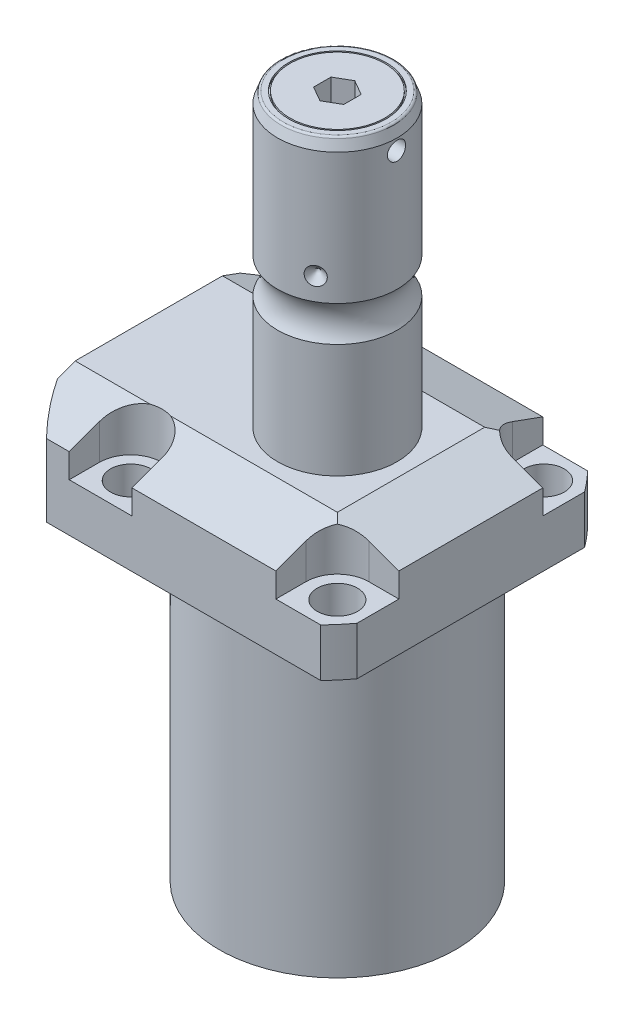
from build123d import *

# Parameters (mm, degrees)
SKETCH1_W               = 70.866
SKETCH1_H               = 85.496
EXTRUDE1_DEPTH          = 104.4448
SKETCH2_OUTSIDE_W       = 117.986
SKETCH2_OUTSIDE_H       = 103.356
SKETCH2_OUTSIDE_R       = 50.8
CUT_EXTRUDE1_DEPTH      = 105.4448
SKETCH3_W               = 45.1992
SKETCH3_H               = 79.4258
FILLET1_R               = 0.381
CUT_EXTRUDE2_DEPTH      = 12.243
CUT_EXTRUDE9_START      = -51.063
CUT_EXTRUDE9_DEPTH      = 87.496
CUT_EXTRUDE7_DEPTH      = 36.433
CUT_EXTRUDE7_DEPTH_BACK = 36.433
SKETCH10_R              = 1.1811
SKETCH17_W              = 5.3594
SKETCH17_H              = 12.776
HOLE1_AT_2_COUNT        = 2
HOLE1_AT_2_PITCH        = 54.864
HOLE1_AT_3_COUNT        = 2
HOLE1_AT_3_PITCH        = 77.589412886
HOLE1_AT_4_COUNT        = 2
HOLE1_AT_4_PITCH        = 54.864
CHAMFER1_SIZE           = 0.635
SKETCH22_R              = 6.35
EXTRUDE2_DEPTH          = 1.651
FILLET2_R               = 0.635
SKETCH24_R              = 12.954
SKETCH24_R_2            = 12.573
CUT_EXTRUDE10_DEPTH     = 0.49999999
CUT_EXTRUDE11_DEPTH     = 8
CIRPATTERN1_COUNT       = 3
SKETCH27_W              = 3.81
SKETCH27_H              = 2.413
CHAMFER2_SIZE           = 1.016


with BuildPart() as part:
    # Sketch1 → Extrude1 (new body)
    with BuildSketch(Plane(origin=(0, 0, 0), x_dir=(0, 0, 1), z_dir=(0, -1, 0))):
        with Locations((0, 7.315)):
            Rectangle(SKETCH1_W, SKETCH1_H)
    extrude(amount=-EXTRUDE1_DEPTH)

    # Sketch2 outside → Cut-Extrude1 (cut, through all)
    with BuildSketch(Plane.XZ):
        with Locations((-7.315, 0)):
            Rectangle(SKETCH2_OUTSIDE_W, SKETCH2_OUTSIDE_H)
        with Locations((-5.4102, 0)):
            Circle(SKETCH2_OUTSIDE_R, mode=Mode.SUBTRACT)
    extrude(amount=-CUT_EXTRUDE1_DEPTH, mode=Mode.SUBTRACT)

    # Sketch3 → Cut-Revolve1 (revolve, cut)
    with BuildSketch(Plane(origin=(0, 0, 0), x_dir=(0, 0, -1), z_dir=(1, 0, 0))):
        with Locations((53.9941, 39.7129)):
            Rectangle(SKETCH3_W, SKETCH3_H)
    revolve(axis=Axis((0, -93.345, 0), (0, 1, 0)), mode=Mode.SUBTRACT)

    # Fillet1
    fillet1_edges = [part.edges().sort_by_distance(p)[0] for p in [
        (0, 79.4258, 31.3945),
    ]]
    fillet(fillet1_edges, radius=FILLET1_R)

    # Sketch4 → Cut-Extrude2 (cut)
    with BuildSketch(Plane(origin=(0, 104.4448, 0), x_dir=(-1, 0, 0), z_dir=(0, 1, 0))):
        with BuildLine():
            Line((-19.1008, -35.433), (-19.1008, -27.432))
            ThreePointArc((-19.1008, -27.432), (-21.540951985, -21.540951985), (-27.432, -19.1008))
            Line((-27.432, -19.1008), (-35.433, -19.1008))
            Line((-35.433, -19.1008), (-35.433, -35.433))
            Line((-35.433, -35.433), (-19.1008, -35.433))
        make_face()
        with BuildLine():
            Line((35.7632, -35.433), (19.1008, -35.433))
            Line((19.1008, -35.433), (19.1008, -27.432))
            ThreePointArc((19.1008, -27.432), (27.432, -19.1008), (35.7632, -27.432))
            Line((35.7632, -27.432), (35.7632, -35.433))
        make_face()
        with BuildLine():
            Line((19.1008, 35.433), (19.1008, 27.432))
            ThreePointArc((19.1008, 27.432), (27.432, 19.1008), (35.7632, 27.432))
            Line((35.7632, 27.432), (35.7632, 35.433))
            Line((35.7632, 35.433), (19.1008, 35.433))
        make_face()
        with BuildLine():
            Line((-27.432, 19.1008), (-35.433, 19.1008))
            Line((-35.433, 19.1008), (-35.433, 35.433))
            Line((-35.433, 35.433), (-19.1008, 35.433))
            Line((-19.1008, 35.433), (-19.1008, 27.432))
            ThreePointArc((-19.1008, 27.432), (-21.540951985, 21.540951985), (-27.432, 19.1008))
        make_face()
    extrude(amount=-CUT_EXTRUDE2_DEPTH, mode=Mode.SUBTRACT)

    # Sketch5 → Cut-Extrude9 (cut)
    with BuildSketch(Plane(origin=(0, 0, 0), x_dir=(0, 0, -1), z_dir=(1, 0, 0)).offset(CUT_EXTRUDE9_START)):
        Polygon((-19.558, 104.4448), (-35.433, 98.666772531), (-35.433, 104.4448), align=None)
    cut_extrude9 = extrude(amount=CUT_EXTRUDE9_DEPTH, mode=Mode.SUBTRACT)

    # Mirror1: Cut-Extrude9 across plane
    add(cut_extrude9.mirror(Plane.XY), mode=Mode.SUBTRACT)

    # Sketch9 → Cut-Extrude7 (cut, two sides)
    with BuildSketch(Plane.XY) as cut_extrude7_sk:
        Polygon((19.558, 104.4448), (35.433, 98.666772531), (35.433, 104.4448), align=None)
    extrude(amount=CUT_EXTRUDE7_DEPTH, mode=Mode.SUBTRACT)
    extrude(cut_extrude7_sk.sketch, amount=-CUT_EXTRUDE7_DEPTH_BACK, mode=Mode.SUBTRACT)

    # Sketch20 → Cut-Revolve4 (revolve, cut)
    with BuildSketch(Plane(origin=(-35.0774, 88.9, -18.1102), x_dir=(0, 1, 0), z_dir=(1, 0, 0)), mode=Mode.PRIVATE) as cut_revolve4_sk:
        Polygon((-9.4742, 38.3413), (-8.0264, 38.3413), (-8.0264, 35.8902), (-7.0104, 35.8902), (-7.0104, 33.8836), (3.9624, 33.8836), (3.9624, 32.639), (-9.4742, 32.639), align=None)
    cut_revolve4 = revolve(cut_revolve4_sk.sketch.rotate(Axis((-35.0774, 81.620304954, 14.5288), (0, 1, 0)), 180), axis=Axis((-35.0774, 81.620304954, 14.5288), (0, 1, 0)), mode=Mode.SUBTRACT)  # turned: the seam where the file's is

    # Mirror10: Cut-Revolve4 across plane
    add(cut_revolve4.mirror(Plane.XY), mode=Mode.SUBTRACT)

    # Sketch15 → Revolve3 (revolve)
    with BuildSketch(Plane(origin=(0, 0, 0), x_dir=(0, 0, -1), z_dir=(1, 0, 0)), mode=Mode.PRIVATE) as revolve3_sk:
        with BuildLine():
            Line((0, 104.4448), (15.875, 104.4448))
            Line((15.875, 104.4448), (15.875, 134.68810643))
            ThreePointArc((15.875, 134.68810643), (14.3256, 139.3952), (15.875, 144.10229357))
            Line((15.875, 144.10229357), (15.875, 178.89219416))
            Line((15.875, 178.89219416), (14.81184082, 181.8132))
            Line((14.81184082, 181.8132), (0, 181.8132))
            Line((0, 181.8132), (0, 104.4448))
        make_face()
    revolve(revolve3_sk.sketch.rotate(Axis((0, 250.290824608, 0), (0, -1, 0)), 180), axis=Axis((0, 250.290824608, 0), (0, -1, 0)))  # turned: the seam where the file's is

    # Sketch17 → Hole1 (revolve, cut)
    with BuildSketch(Plane(origin=(27.432, 92.2018, -27.432), x_dir=(0, 0, 1), z_dir=(1, 0, 0))):
        with Locations((2.6797, 6.388)):
            Rectangle(SKETCH17_W, SKETCH17_H)
    hole1 = revolve(axis=Axis((27.432, -17.7982, -27.432), (0, 1, 0)), mode=Mode.SUBTRACT)

    # Hole1 at 2: Hole1 ×2
    with Locations(*[(0, 0, i * HOLE1_AT_2_PITCH) for i in range(1, HOLE1_AT_2_COUNT)]):
        add(hole1, mode=Mode.SUBTRACT)

    # Hole1 at 3: Hole1 ×2
    with Locations(*[Vector(-0.707106781, 0, 0.707106781) * (i * HOLE1_AT_3_PITCH) for i in range(1, HOLE1_AT_3_COUNT)]):
        add(hole1, mode=Mode.SUBTRACT)

    # Hole1 at 4: Hole1 ×2
    with Locations(*[(-i * HOLE1_AT_4_PITCH, 0, 0) for i in range(1, HOLE1_AT_4_COUNT)]):
        add(hole1, mode=Mode.SUBTRACT)

    # Chamfer1
    chamfer1_edges = [part.edges().sort_by_distance(p)[0] for p in [
        (-35.0774, 81.8896, 15.7734),
        (-35.0774, 81.8896, -15.7734),
    ]]
    chamfer(chamfer1_edges, length=CHAMFER1_SIZE)

    # Sketch21 → Cut-Revolve5 (revolve, cut)
    with BuildSketch(Plane.XZ.offset(-91.9226)):
        Polygon((-50.063, -2.5019), (-49.809, -2.5019), (-49.809, -6.7564), (-47.2563, -7.440393904), (-46.695693904, -8.001), (-30.759, -8.001), (-30.759, -12.9794), (-50.063, -12.9794), align=None)
    cut_revolve5 = revolve(axis=Axis((-57.549532301, 91.9226, -12.9794), (1, 0, 0)), mode=Mode.SUBTRACT)

    # Mirror13: Cut-Revolve5 across plane
    add(cut_revolve5.mirror(Plane.XY), mode=Mode.SUBTRACT)

    # Sketch22 → Extrude2 (add)
    with BuildSketch(Plane.ZY.offset(49.809)):
        with Locations((-12.9794, 91.9226)):
            Circle(SKETCH22_R)
    extrude(amount=EXTRUDE2_DEPTH)

    # Fillet2
    fillet2_edges = [part.edges().sort_by_distance(p)[0] for p in [
        (0, 181.8132, -14.81184082),
    ]]
    fillet(fillet2_edges, radius=FILLET2_R)

    # Sketch24 → Cut-Extrude10 (cut)
    with BuildSketch(Plane(origin=(0, 181.8132, 0), x_dir=(1, 0, 0), z_dir=(0, 1, 0))):
        with Locations(Location((0, 0, 0), (0, 0, 270))):  # turned: the seam where the file's is
            Circle(SKETCH24_R)
        with Locations(Location((0, 0, 0), (0, 0, 270))):  # turned: the seam where the file's is
            Circle(SKETCH24_R_2, mode=Mode.SUBTRACT)
    extrude(amount=-CUT_EXTRUDE10_DEPTH, mode=Mode.SUBTRACT)

    # Sketch25 → Cut-Extrude11 (cut)
    with BuildSketch(Plane(origin=(0, 181.8132, 0), x_dir=(1, 0, 0), z_dir=(0, 1, 0))):
        Polygon((4, -2.309401077), (4, 2.309401077), (0, 4.618802154), (-4, 2.309401077), (-4, -2.309401077), (0, -4.618802154), align=None)
    extrude(amount=-CUT_EXTRUDE11_DEPTH, mode=Mode.SUBTRACT)

    # Sketch26 → Cut-Revolve7 (revolve, cut)
    with BuildSketch(Plane.XY, mode=Mode.PRIVATE) as cut_revolve7_sk:
        Polygon((-15.875, 152.4762), (-13.462, 150.0632), (-15.875, 150.0632), align=None)
    cut_revolve7 = revolve(cut_revolve7_sk.sketch.rotate(Axis((-39.772000707, 150.0632, 0), (1, 0, 0)), 90), axis=Axis((-39.772000707, 150.0632, 0), (1, 0, 0)), mode=Mode.SUBTRACT)  # turned: the seam where the file's is

    # CirPattern1: Cut-Revolve7 ×3 about axis
    cirpattern1_axis = Axis((0, 250.290824608, 0), (0, 1, 0))
    for i in range(1, CIRPATTERN1_COUNT):
        add(cut_revolve7.rotate(cirpattern1_axis, i * 360 / CIRPATTERN1_COUNT), mode=Mode.SUBTRACT)

    # Sketch27 → Cut-Revolve8 (revolve, cut)
    with BuildSketch(Plane.XY, mode=Mode.PRIVATE) as cut_revolve8_sk:
        with Locations((13.97, 177.1777)):
            Rectangle(SKETCH27_W, SKETCH27_H)
    revolve(cut_revolve8_sk.sketch.rotate(Axis((5.37407372, 175.9712, 0), (1, 0, 0)), 90), axis=Axis((5.37407372, 175.9712, 0), (1, 0, 0)), mode=Mode.SUBTRACT)  # turned: the seam where the file's is

    # Chamfer2
    chamfer2_edges = [part.edges().sort_by_distance(p)[0] for p in [
        (-51.46, 91.9226, -19.3294),
    ]]
    chamfer(chamfer2_edges, length=CHAMFER2_SIZE)


with BuildPart() as body_2:
    # Sketch10 → Revolve4 (revolve)
    with BuildSketch(Plane(origin=(-35.0774, 88.9, -18.1102), x_dir=(0, 1, 0), z_dir=(1, 0, 0))):
        with Locations((-9.2075, 8.1026)):
            Circle(SKETCH10_R)
    revolve(axis=Axis((-35.0774, 87.86749, -14.5288), (0, 1, 0)))


with BuildPart() as body_3:
    # Mirror12: mirrored copy
    add(body_2.part.mirror(Plane.XY))


solid = Compound([part.part, body_2.part, body_3.part])
